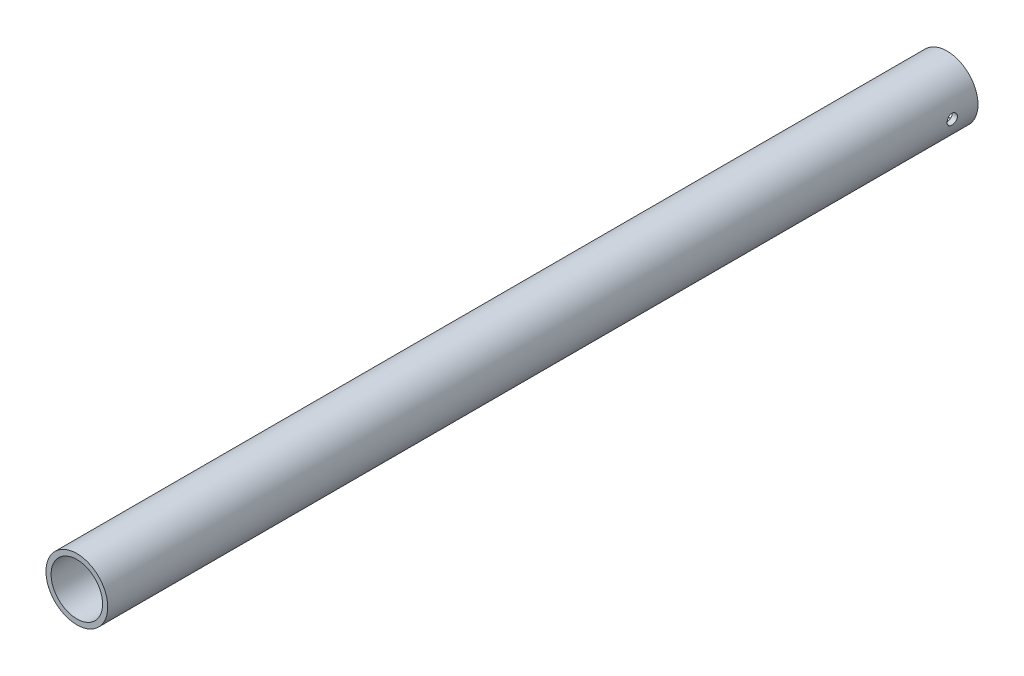
from build123d import *

# Parameters (mm, degrees)
SKETCH1_R                  = 6
SKETCH1_R_2                = 5
BOSS_EXTRUDE1_DEPTH        = 169
IZIM1_R                    = 1
KES_EKSTR_ZYON1_DEPTH      = 7
KES_EKSTR_ZYON1_DEPTH_BACK = 7


with BuildPart() as part:
    # Sketch1 → Boss-Extrude1 (new body)
    with BuildSketch(Plane.XY):
        Circle(SKETCH1_R)
        Circle(SKETCH1_R_2, mode=Mode.SUBTRACT)
    extrude(amount=BOSS_EXTRUDE1_DEPTH)

    # Çizim1 → Kes-Ekstrüzyon1 (cut, two sides)
    with BuildSketch(Plane(origin=(0, 0, 0), x_dir=(0, 0, -1), z_dir=(1, 0, 0))) as kes_ekstr_zyon1_sk:
        with Locations((-5, 0)):
            Circle(IZIM1_R)
    extrude(amount=KES_EKSTR_ZYON1_DEPTH, mode=Mode.SUBTRACT)
    extrude(kes_ekstr_zyon1_sk.sketch, amount=-KES_EKSTR_ZYON1_DEPTH_BACK, mode=Mode.SUBTRACT)


solid = part.part
